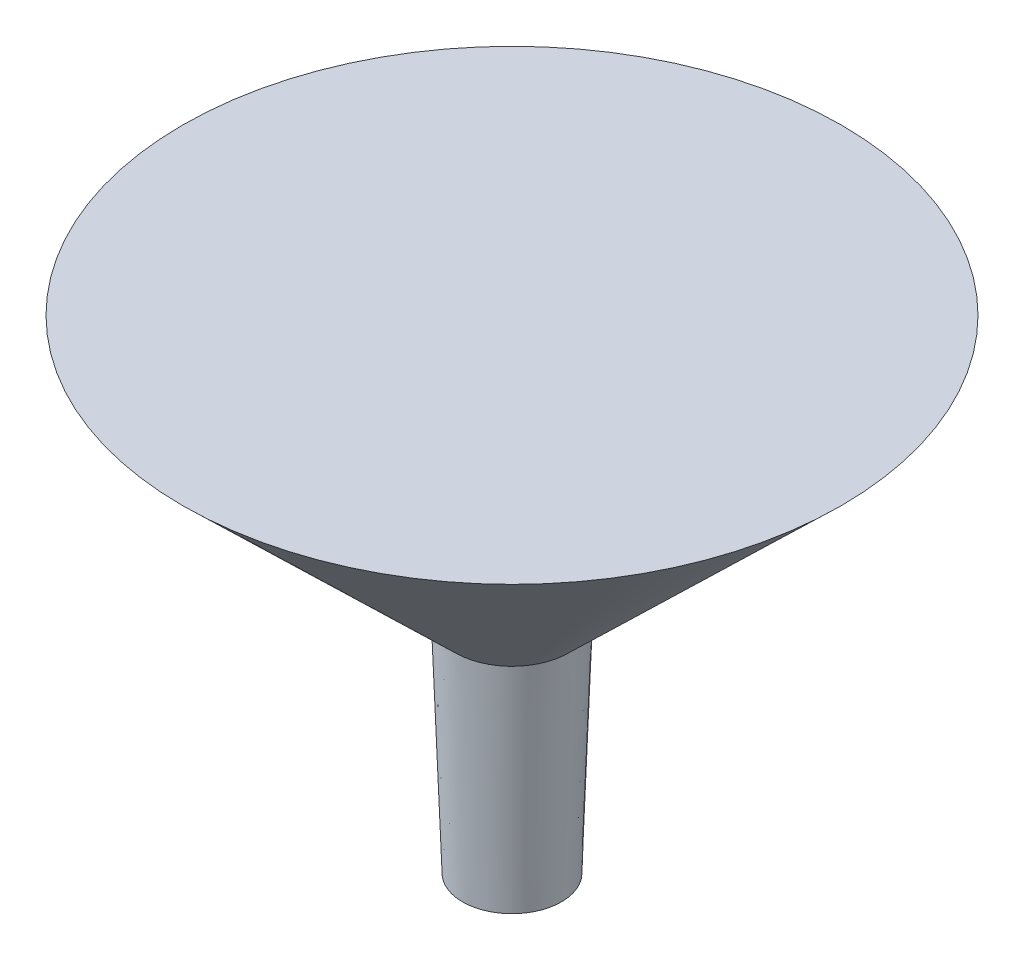
from build123d import *


with BuildPart() as part:
    # Sketch1 → Revolve1 (revolve)
    with BuildSketch(Plane(origin=(0, 0, 0), x_dir=(0, 0, -1), z_dir=(1, 0, 0))):
        Polygon((0, 13.97), (0, -13.97), (2.858506227, -13.97), (3.302, -1.27), (19.05, 13.97), align=None)
    revolve(axis=Axis((0, 13.97, 0), (0, -1, 0)))


solid = part.part
